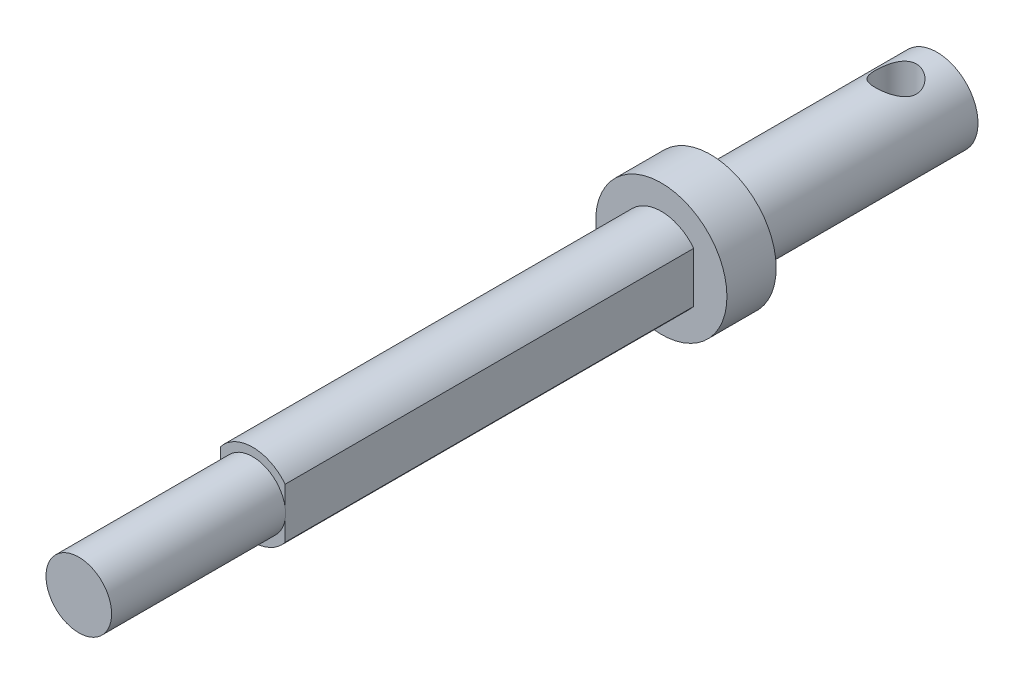
from build123d import *

# Parameters (mm, degrees)
SKETCH1_R               = 2.5
BOSS_EXTRUDE1_DEPTH     = 13.8
BOSS_EXTRUDE3_START     = 13.8
SKETCH1_4_R             = 4
BOSS_EXTRUDE3_DEPTH     = 3
BOSS_EXTRUDE2_START     = 16.8
BOSS_EXTRUDE2_DEPTH     = 24.9
SKETCH2_R               = 2
BOSS_EXTRUDE4_DEPTH     = 10.6
SKETCH17_R              = 1.25
CUT_EXTRUDE1_DEPTH      = 53.605037782
CUT_EXTRUDE1_DEPTH_BACK = 53.605037782


with BuildPart() as part:
    # Sketch1 → Boss-Extrude1 (new body)
    with BuildSketch(Plane.XY):
        with Locations(Location((0, 0, 0), (0, 0, 180))):
            Circle(SKETCH1_R)
    extrude(amount=BOSS_EXTRUDE1_DEPTH)

    # Sketch1_4 → Boss-Extrude3 (add)
    with BuildSketch(Plane.XY.offset(BOSS_EXTRUDE3_START)):
        Circle(SKETCH1_4_R)
    extrude(amount=BOSS_EXTRUDE3_DEPTH)

    # Sketch1_3 → Boss-Extrude2 (add)
    with BuildSketch(Plane.XY.offset(BOSS_EXTRUDE2_START)):
        with BuildLine():
            ThreePointArc((0, -2.5), (1.099564058, -2.245207982), (1.975, -1.532767106))
            Line((1.975, -1.532767106), (1.975, 1.532767106))
            ThreePointArc((1.975, 1.532767106), (0, 2.5), (-1.975, 1.532767106))
            Line((-1.975, 1.532767106), (-1.975, -1.532767106))
            ThreePointArc((-1.975, -1.532767106), (-1.099564058, -2.245207982), (0, -2.5))
        make_face()
    extrude(amount=BOSS_EXTRUDE2_DEPTH)

    # Sketch2 → Boss-Extrude4 (add)
    with BuildSketch(Plane.XY.offset(41.7)):
        with Locations(Location((0, 0, 0), (0, 0, 170.931278454))):
            Circle(SKETCH2_R)
    extrude(amount=BOSS_EXTRUDE4_DEPTH)

    # Sketch17 → Cut-Extrude1 (cut, two sides)
    with BuildSketch(Plane(origin=(0, 0, 0), x_dir=(1, 0, 0), z_dir=(0, 1, 0))) as cut_extrude1_sk:
        with Locations(Location((0, -2.5, 0), (0, 0, 270))):
            Circle(SKETCH17_R)
    extrude(amount=CUT_EXTRUDE1_DEPTH, mode=Mode.SUBTRACT)
    extrude(cut_extrude1_sk.sketch, amount=-CUT_EXTRUDE1_DEPTH_BACK, mode=Mode.SUBTRACT)


solid = part.part
